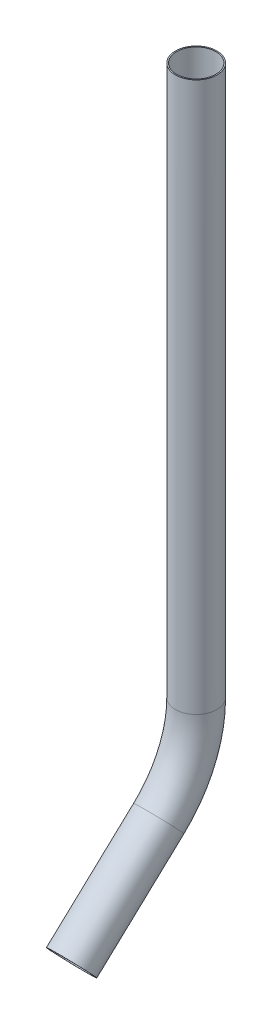
from build123d import *

# Parameters (mm, degrees)
SKETCH1_R   = 6.731
SKETCH1_R_2 = 6.35


with BuildPart() as part:
    # Sweep1: sweep along a path in Sketch2
    with BuildLine(Plane(origin=(0, 0, 0), x_dir=(0, 0, -1), z_dir=(1, 0, 0))) as sweep1_path:
        Line((0, 0), (0, -177.8))
        ThreePointArc((0, -177.8), (-3.159191381, -192.99045401), (-12.112855277, -205.661771465))
        Line((-12.112855277, -205.661771465), (-40.315635139, -231.966980478))
    # Sketch1 → Sweep1 (sweep)
    with BuildSketch(Plane(origin=(0, 0, 0), x_dir=(1, 0, 0), z_dir=(0, 1, 0))):
        Circle(SKETCH1_R)
        Circle(SKETCH1_R_2, mode=Mode.SUBTRACT)
    sweep(path=sweep1_path.line)


solid = part.part
